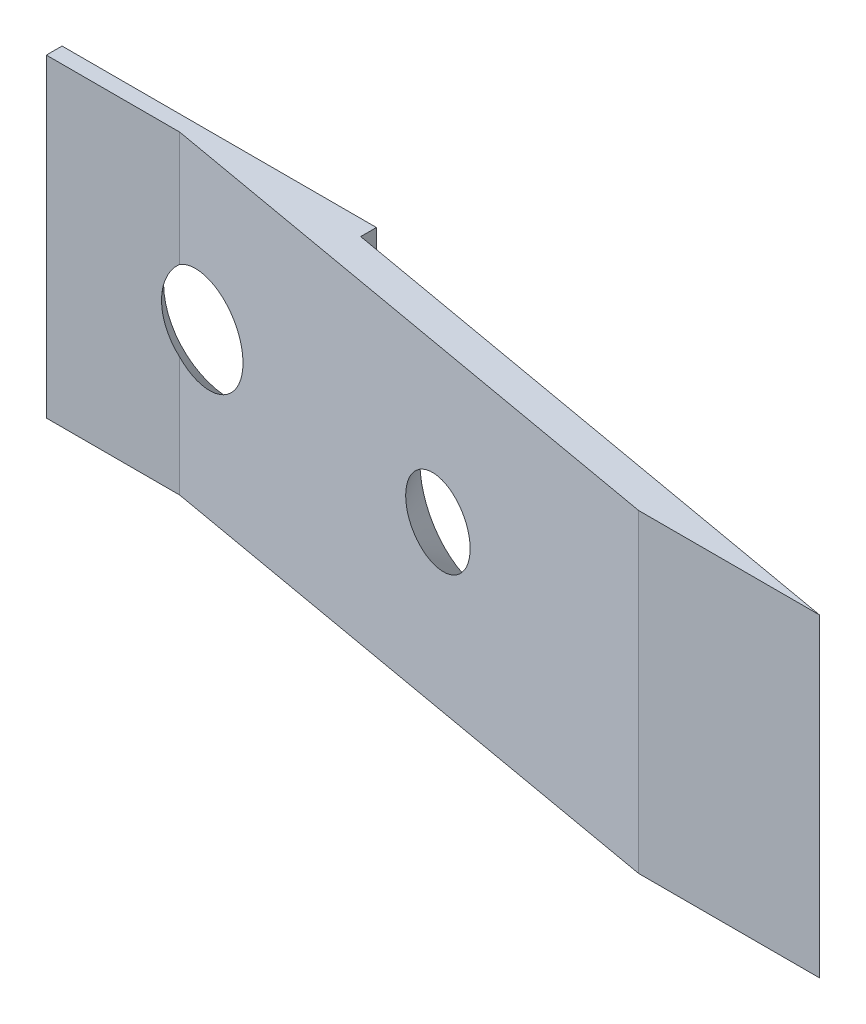
from build123d import *

# Parameters (mm, degrees)
SKETCH2_W                                         = 10
SKETCH2_H                                         = 10
BOSS_EXTRUDE1_DEPTH                               = 0.5
BOSS_EXTRUDE2_DEPTH                               = 10
CSK_FOR_1_FLAT_HEAD_SOCKET_CAP_SCREW1_D           = 2.0574
CSK_FOR_1_FLAT_HEAD_SOCKET_CAP_SCREW1_CSINK_D     = 4.2672
CSK_FOR_1_FLAT_HEAD_SOCKET_CAP_SCREW1_CSINK_ANGLE = 82
CSK_FOR_1_FLAT_HEAD_SOCKET_CAP_SCREW2_D           = 2.0574
CSK_FOR_1_FLAT_HEAD_SOCKET_CAP_SCREW2_CSINK_D     = 4.2672
CSK_FOR_1_FLAT_HEAD_SOCKET_CAP_SCREW2_CSINK_ANGLE = 82


with BuildPart() as part:
    # Sketch2 → Boss-Extrude1 (new body)
    with BuildSketch(Plane.XY):
        with Locations((5, -5)):
            Rectangle(SKETCH2_W, SKETCH2_H)
    extrude(amount=BOSS_EXTRUDE1_DEPTH)

    # Sketch3 → Boss-Extrude2 (add)
    with BuildSketch(Plane.XZ.offset(10)):
        Polygon((4.241229517, 0.5), (21.967769071, 3.625667198), (27.726539554, 3.625667198), (10, 0.5), align=None)
    extrude(amount=-BOSS_EXTRUDE2_DEPTH)

    # CSK for #1 Flat Head Socket Cap Screw1 (through all)
    with Locations(Plane(origin=(0, 0, 0), x_dir=(-1, 0, 0), z_dir=(0, 0, -1))):
        with Locations((-5.362516401, -4.921292394)):
            CounterSinkHole(CSK_FOR_1_FLAT_HEAD_SOCKET_CAP_SCREW1_D / 2, CSK_FOR_1_FLAT_HEAD_SOCKET_CAP_SCREW1_CSINK_D / 2, counter_sink_angle=CSK_FOR_1_FLAT_HEAD_SOCKET_CAP_SCREW1_CSINK_ANGLE)

    # CSK for #1 Flat Head Socket Cap Screw2 (through all)
    with Locations(Plane(origin=(0.21603186, 0, -1.225177561), x_dir=(-0.984807753, 0, -0.173648178), z_dir=(0.173648178, 0, -0.984807753))):
        with Locations((-14.39146791, -4.879407471)):
            CounterSinkHole(CSK_FOR_1_FLAT_HEAD_SOCKET_CAP_SCREW2_D / 2, CSK_FOR_1_FLAT_HEAD_SOCKET_CAP_SCREW2_CSINK_D / 2, counter_sink_angle=CSK_FOR_1_FLAT_HEAD_SOCKET_CAP_SCREW2_CSINK_ANGLE)


solid = part.part
